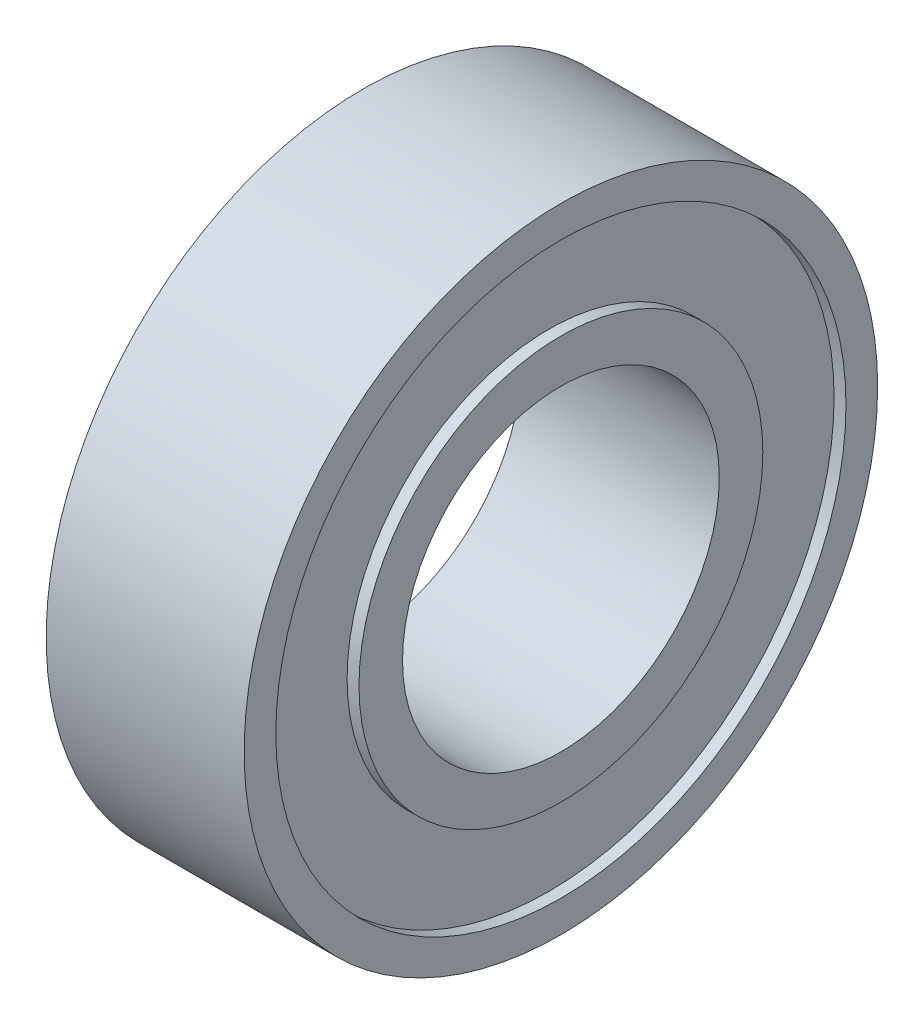
from build123d import *


with BuildPart() as part:
    # Sketch1 → Revolve1 (revolve)
    with BuildSketch(Plane.XY):
        Polygon((2.5, 4), (-2.5, 4), (-2.5, 5.1), (-2.2, 5.1), (-2.2, 7.2), (-2.5, 7.2), (-2.5, 8), (2.5, 8), (2.5, 7.2), (2.2, 7.2), (2.2, 5.1), (2.5, 5.1), align=None)
    revolve(axis=Axis((0, 0, 0), (-1, 0, 0)))


solid = part.part
